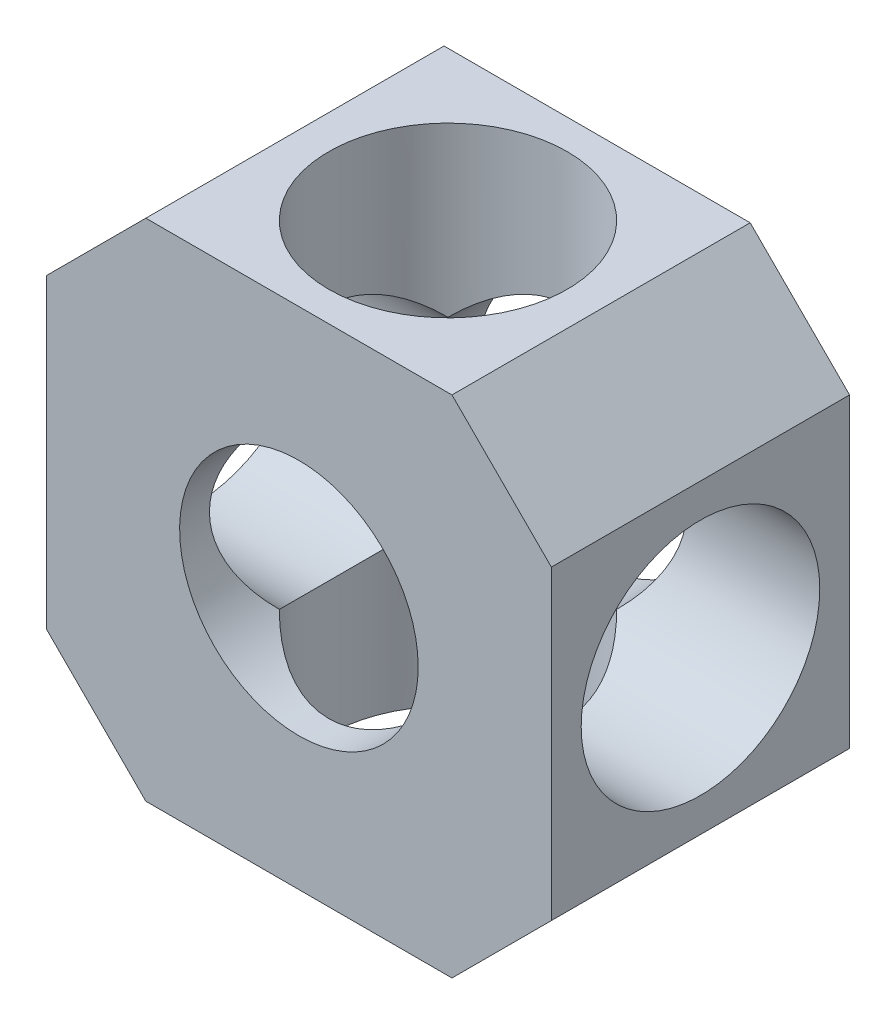
from build123d import *

# Parameters (mm, degrees)
SKETCH2_R           = 6
BOSS_EXTRUDE1_DEPTH = 15
SKETCH3_R           = 6
CUT_EXTRUDE1_DEPTH  = 27
SKETCH4_R           = 6
CUT_EXTRUDE2_DEPTH  = 27


with BuildPart() as part:
    # Sketch2 → Boss-Extrude1 (new body)
    with BuildSketch(Plane.XY):
        Polygon((0, 20.4), (5, 25.4), (20.4, 25.4), (25.4, 20.4), (25.4, 5), (20.4, 0), (5, 0), (0, 5), align=None)
        with Locations((12.7, 12.7)):
            Circle(SKETCH2_R, mode=Mode.SUBTRACT)
    extrude(amount=BOSS_EXTRUDE1_DEPTH)

    # Sketch3 → Cut-Extrude1 (cut)
    with BuildSketch(Plane(origin=(25.4, 0, 0), x_dir=(0, 0, -1), z_dir=(1, 0, 0))):
        with Locations((-7.5, 12.7)):
            Circle(SKETCH3_R)
    extrude(amount=-CUT_EXTRUDE1_DEPTH, mode=Mode.SUBTRACT)

    # Sketch4 → Cut-Extrude2 (cut)
    with BuildSketch(Plane(origin=(0, 25.4, 0), x_dir=(1, 0, 0), z_dir=(0, 1, 0))):
        with Locations((12.7, -7.5)):
            Circle(SKETCH4_R)
    extrude(amount=-CUT_EXTRUDE2_DEPTH, mode=Mode.SUBTRACT)


solid = part.part
